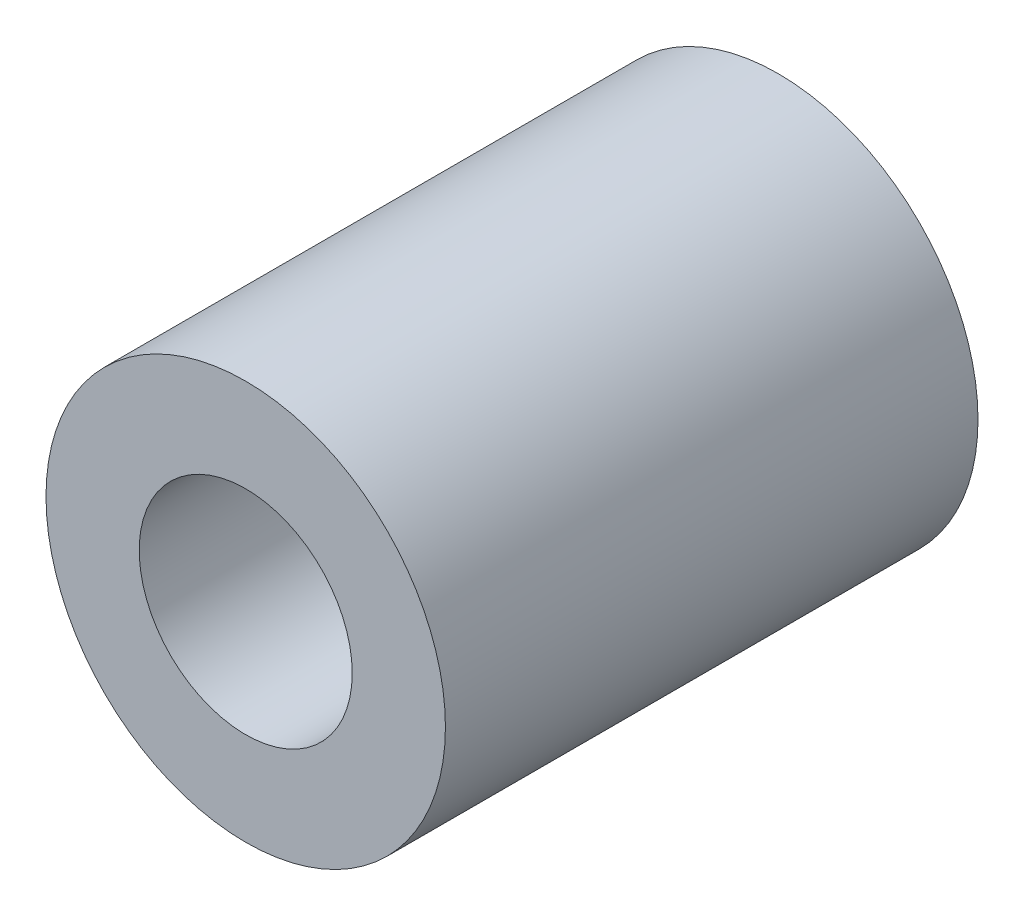
from build123d import *

# Parameters (mm, degrees)
SKETCH1_R           = 3
SKETCH1_R_2         = 1.6
BOSS_EXTRUDE1_DEPTH = 8


with BuildPart() as part:
    # Sketch1 → Boss-Extrude1 (new body)
    with BuildSketch(Plane.XY):
        Circle(SKETCH1_R)
        Circle(SKETCH1_R_2, mode=Mode.SUBTRACT)
    extrude(amount=BOSS_EXTRUDE1_DEPTH)


solid = part.part
